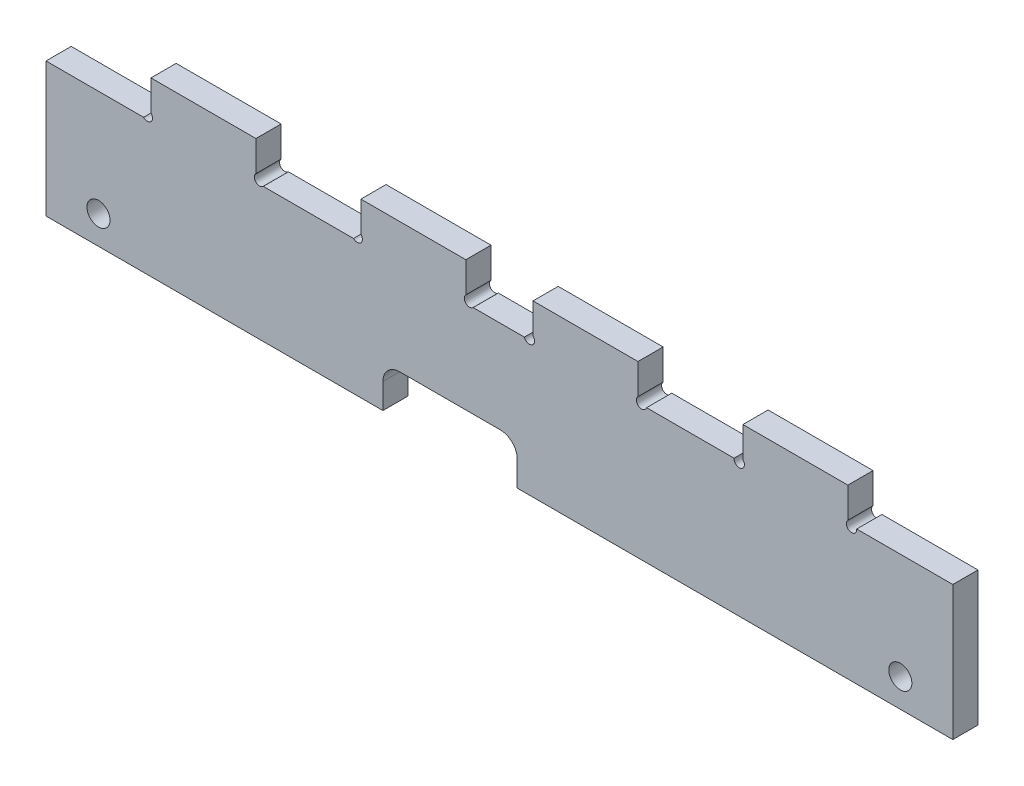
from build123d import *

# Parameters (mm, degrees)
CROQUIS1_R              = 5.5
SALIENTE_EXTRUIR1_DEPTH = 12


with BuildPart() as part:
    # Croquis1 → Saliente-Extruir1 (new body)
    with BuildSketch(Plane.XY):
        with BuildLine():
            Line((-181.041600866, 72.635135135), (-134.541600866, 72.635135135))
            ThreePointArc((-134.541600866, 72.635135135), (-131.041600866, 72.635135135), (-131.041600866, 76.135135135))
            Line((-131.041600866, 76.135135135), (-131.041600866, 90.635135135))
            Line((-131.041600866, 90.635135135), (-81.041600866, 90.635135135))
            Line((-81.041600866, 90.635135135), (-81.041600866, 76.135135135))
            ThreePointArc((-81.041600866, 76.135135135), (-81.041600866, 72.635135135), (-77.541600866, 72.635135135))
            Line((-77.541600866, 72.635135135), (-34.541600866, 72.635135135))
            ThreePointArc((-34.541600866, 72.635135135), (-31.041600866, 72.635135135), (-31.041600866, 76.135135135))
            Line((-31.041600866, 76.135135135), (-31.041600866, 90.635135135))
            Line((-31.041600866, 90.635135135), (18.958399134, 90.635135135))
            Line((18.958399134, 90.635135135), (18.958399134, 76.135135135))
            ThreePointArc((18.958399134, 76.135135135), (18.958399134, 72.635135135), (22.458399134, 72.635135135))
            Line((22.458399134, 72.635135135), (46.849903851, 72.635135135))
            ThreePointArc((46.849903851, 72.635135135), (50.494893062, 71.270913441), (50.958399134, 75.135135135))
            Line((50.958399134, 75.135135135), (50.958399134, 89.635135135))
            Line((50.958399134, 89.635135135), (100.958399134, 89.635135135))
            Line((100.958399134, 89.635135135), (100.958399134, 75.135135135))
            ThreePointArc((100.958399134, 75.135135135), (101.421905205, 71.270913441), (105.066894417, 72.635135135))
            Line((105.066894417, 72.635135135), (146.746184683, 72.635135135))
            ThreePointArc((146.746184683, 72.635135135), (150.038647504, 70.053679014), (150.958399134, 74.135135135))
            Line((150.958399134, 74.135135135), (150.958399134, 88.635135135))
            Line((150.958399134, 88.635135135), (200.958399134, 88.635135135))
            Line((200.958399134, 88.635135135), (200.958399134, 74.135135135))
            ThreePointArc((200.958399134, 74.135135135), (201.878150764, 70.053679014), (205.170613584, 72.635135135))
            Line((205.170613584, 72.635135135), (250.958399134, 72.635135135))
            Line((250.958399134, 72.635135135), (250.958399134, 8.635135135))
            Line((250.958399134, 8.635135135), (43.458399134, 8.635135135))
            Line((43.458399134, 8.635135135), (43.458399134, 20.635135135))
            ThreePointArc((43.458399134, 20.635135135), (41.115253383, 26.291989385), (35.458399134, 28.635135135))
            Line((35.458399134, 28.635135135), (-12.541600866, 28.635135135))
            ThreePointArc((-12.541600866, 28.635135135), (-18.198455116, 26.291989385), (-20.541600866, 20.635135135))
            Line((-20.541600866, 20.635135135), (-20.541600866, 8.635135135))
            Line((-20.541600866, 8.635135135), (-181.041600866, 8.635135135))
            Line((-181.041600866, 8.635135135), (-181.041600866, 72.635135135))
        make_face()
        with Locations((-156.041600866, 22.135135135)):
            Circle(CROQUIS1_R, mode=Mode.SUBTRACT)
        with Locations((225.958399134, 22.135135135)):
            Circle(CROQUIS1_R, mode=Mode.SUBTRACT)
    extrude(amount=SALIENTE_EXTRUIR1_DEPTH)


solid = part.part
